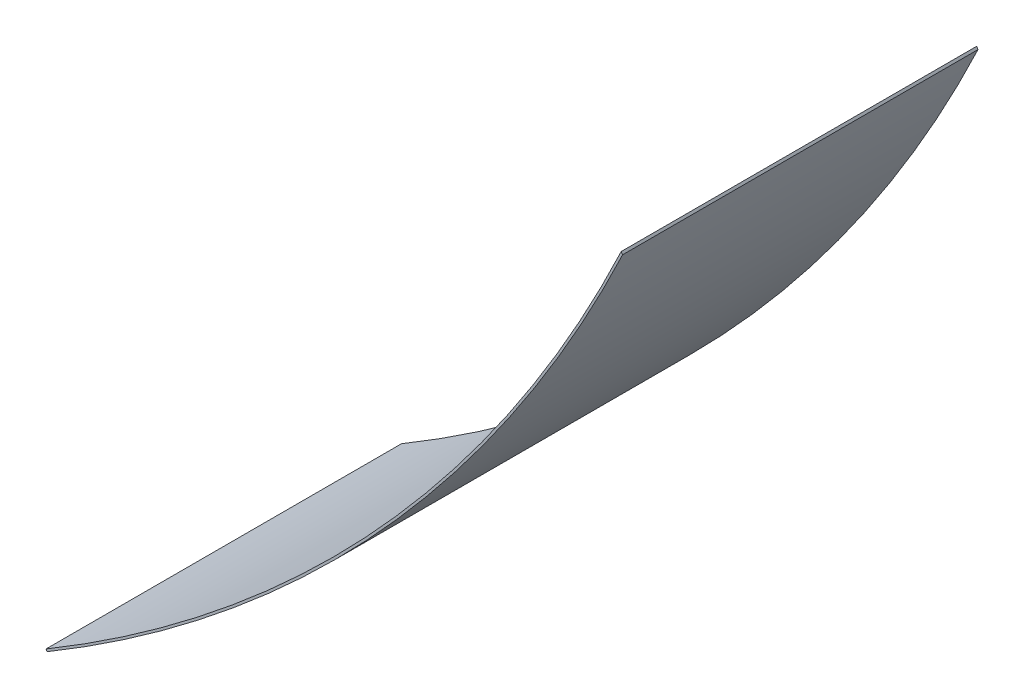
from build123d import *

# Parameters (mm, degrees)
BOSS_EXTRUDE1_DEPTH = 1653.72763


with BuildPart() as part:
    # Sketch1 → Boss-Extrude1 (new body)
    with BuildSketch(Plane.XY):
        with BuildLine():
            Line((2736.813132837, 2975.253232414), (2743.033178483, 2965.026445424))
            ThreePointArc((2743.033178483, 2965.026445424), (1623.319019455, 1296.296733234), (65.481128808, 26.824497722))
            Line((65.481128808, 26.824497722), (60.376401353, 35.423437052))
            ThreePointArc((60.376401353, 35.423437052), (1618.140998777, 1305.462273997), (2736.813132837, 2975.253232414))
        make_face()
    extrude(amount=BOSS_EXTRUDE1_DEPTH)


solid = part.part
